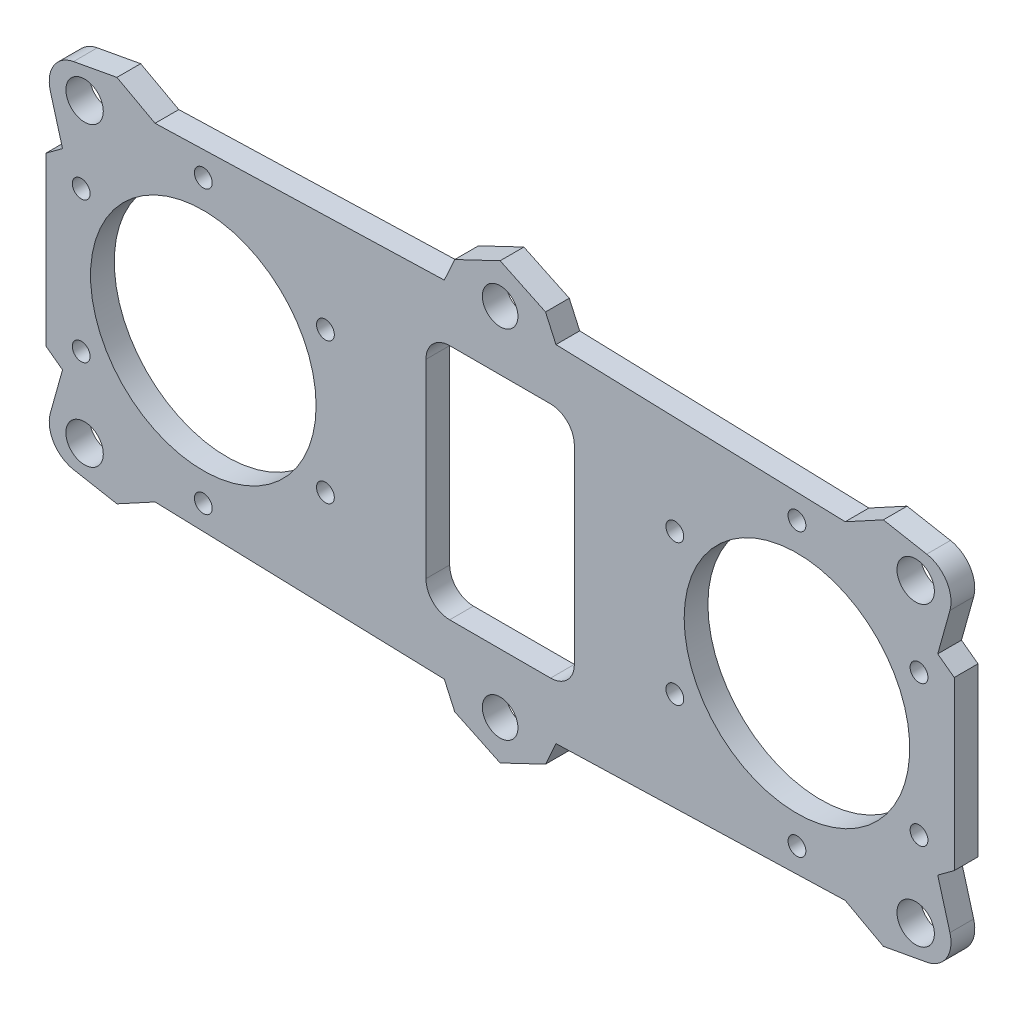
from build123d import *

# Parameters (mm, degrees)
SKETCH1_R           = 3
SKETCH1_R_2         = 19
BOSS_EXTRUDE1_DEPTH = 4
CUT_EXTRUDE1_DEPTH  = 5
SKETCH3_R           = 3.15
BOSS_EXTRUDE2_DEPTH = 4
FILLET1_R           = 5
SKETCH4_R           = 1.5
CUT_EXTRUDE2_DEPTH  = 5


with BuildPart() as part:
    # Sketch1 → Boss-Extrude1 (new body)
    with BuildSketch(Plane.XY):
        Polygon((0, 36.632796194), (-7.647271147, 32.990762303), (-9.405300929, 29.104152359), (-58.126981429, 27.62278105), (-76.5, 14.085859857), (-76.5, -14.085859857), (-58.126981429, -27.62278105), (-9.405300929, -29.104152359), (-7.647271147, -32.990762303), (0, -36.632796194), (7.647271147, -32.990762303), (9.405300929, -29.104152359), (58.126981429, -27.62278105), (76.5, -14.085859857), (76.5, 14.085859857), (58.126981429, 27.62278105), (9.405300929, 29.104152359), (7.647271147, 32.990762303), align=None)
        with Locations((0, 30)):
            Circle(SKETCH1_R, mode=Mode.SUBTRACT)
        with Locations((-50, 0)):
            Circle(SKETCH1_R_2, mode=Mode.SUBTRACT)
        with Locations((50, 0)):
            Circle(SKETCH1_R_2, mode=Mode.SUBTRACT)
        with Locations((0, -30)):
            Circle(SKETCH1_R, mode=Mode.SUBTRACT)
    extrude(amount=BOSS_EXTRUDE1_DEPTH)

    # Sketch2 → Cut-Extrude1 (cut, through all)
    with BuildSketch(Plane.XY.offset(4)):
        with BuildLine():
            Line((8.5, 20), (-8.5, 20))
            ThreePointArc((-8.5, 20), (-11.328427125, 18.828427125), (-12.5, 16))
            Line((-12.5, 16), (-12.5, -16))
            ThreePointArc((-12.5, -16), (-11.328427125, -18.828427125), (-8.5, -20))
            Line((-8.5, -20), (8.5, -20))
            ThreePointArc((8.5, -20), (11.328427125, -18.828427125), (12.5, -16))
            Line((12.5, -16), (12.5, 16))
            ThreePointArc((12.5, 16), (11.328427125, 18.828427125), (8.5, 20))
        make_face()
    extrude(amount=-CUT_EXTRUDE1_DEPTH, mode=Mode.SUBTRACT)

    # Sketch3 → Boss-Extrude2 (add)
    with BuildSketch(Plane.XY.offset(4)):
        Polygon((-58.126981429, 27.62278105), (-64.551915182, 31.10998542), (-77.245081729, 28.773819798), (-73.717039059, 16.136297176), align=None)
        with Locations((-70, 25)):
            Circle(SKETCH3_R, mode=Mode.SUBTRACT)
        Polygon((73.717039059, 16.136297176), (58.126981429, 27.62278105), (64.551915182, 31.10998542), (77.245081729, 28.773819798), align=None)
        with Locations((70, 25)):
            Circle(SKETCH3_R, mode=Mode.SUBTRACT)
        Polygon((58.126981429, -27.62278105), (64.551915182, -31.10998542), (77.245081729, -28.773819798), (73.717039059, -16.136297176), align=None)
        with Locations((70, -25)):
            Circle(SKETCH3_R, mode=Mode.SUBTRACT)
        Polygon((-73.717039059, -16.136297176), (-58.126981429, -27.62278105), (-64.551915182, -31.10998542), (-77.245081729, -28.773819798), align=None)
        with Locations((-70, -25)):
            Circle(SKETCH3_R, mode=Mode.SUBTRACT)
    extrude(amount=-BOSS_EXTRUDE2_DEPTH)

    # Fillet1
    fillet1_edges = [part.edges().sort_by_distance(p)[0] for p in [
        (77.245081729, 28.773819798, 2),
        (77.245081729, -28.773819798, 2),
        (-77.245081729, -28.773819798, 2),
        (-77.245081729, 28.773819798, 2),
    ]]
    fillet(fillet1_edges, radius=FILLET1_R)

    # Sketch4 → Cut-Extrude2 (cut, through all)
    with BuildSketch(Plane.XY.offset(4)):
        with Locations((-50, 23.75)):
            Circle(SKETCH4_R)
        with Locations((-70.56810334, 11.875)):
            Circle(SKETCH4_R)
        with Locations((-70.56810334, -11.875)):
            Circle(SKETCH4_R)
        with Locations((-50, -23.75)):
            Circle(SKETCH4_R)
        with Locations((-29.43189666, -11.875)):
            Circle(SKETCH4_R)
        with Locations((-29.43189666, 11.875)):
            Circle(SKETCH4_R)
        with Locations((29.43189666, 11.875)):
            Circle(SKETCH4_R)
        with Locations((29.43189666, -11.875)):
            Circle(SKETCH4_R)
        with Locations((50, -23.75)):
            Circle(SKETCH4_R)
        with Locations((70.56810334, -11.875)):
            Circle(SKETCH4_R)
        with Locations((70.56810334, 11.875)):
            Circle(SKETCH4_R)
        with Locations((50, 23.75)):
            Circle(SKETCH4_R)
    extrude(amount=-CUT_EXTRUDE2_DEPTH, mode=Mode.SUBTRACT)


solid = part.part
